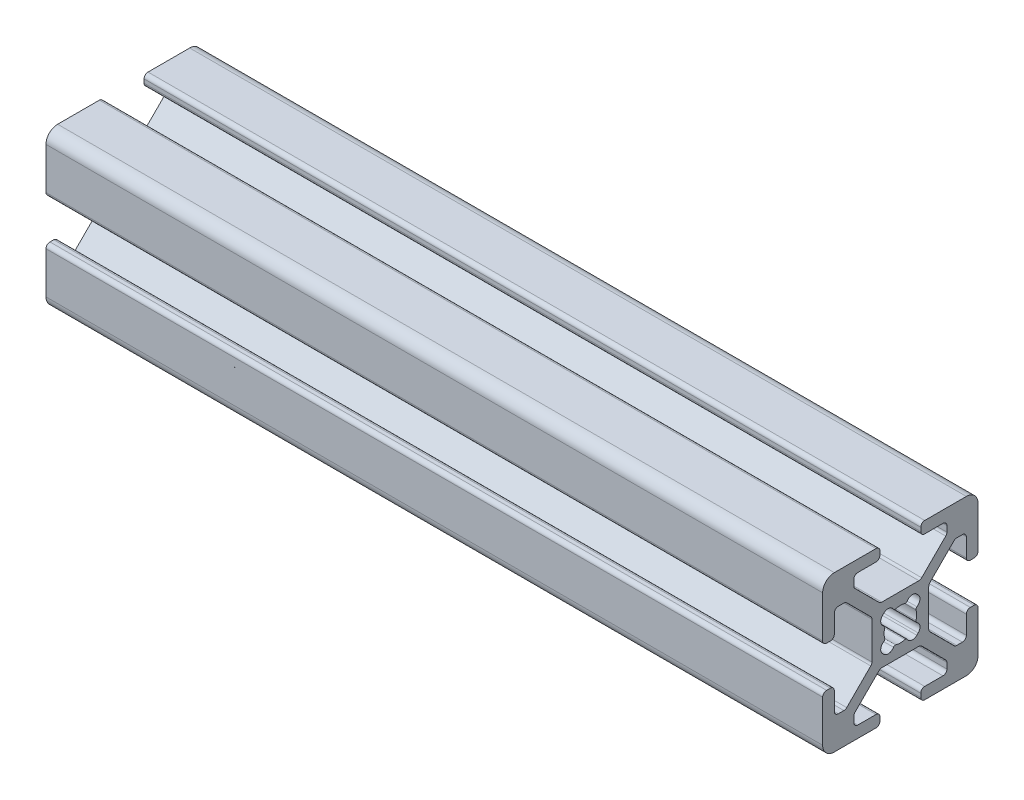
from build123d import *

# Parameters (mm, degrees)
F_20_SERIES_20_2020_1_DEPTH = 100


with BuildPart() as part:
    # Sketch11 → 20_series 20-2020(1) (new body)
    with BuildSketch(Plane.YZ):
        with BuildLine():
            Line((9.0094, 2.6289), (9.492, 2.6289))
            ThreePointArc((9.492, 2.6289), (9.851210245, 2.777689755), (10, 3.1369))
            Line((10, 3.1369), (10, 8.5014))
            ThreePointArc((10, 8.5014), (9.561070222, 9.561070222), (8.5014, 10))
            Line((8.5014, 10), (3.1369, 10))
            ThreePointArc((3.1369, 10), (2.777689755, 9.851210245), (2.6289, 9.492))
            Line((2.6289, 9.492), (2.6289, 9.0094))
            ThreePointArc((2.6289, 9.0094), (2.777689755, 8.650189755), (3.1369, 8.5014))
            Line((3.1369, 8.5014), (5.4864, 8.5014))
            ThreePointArc((5.4864, 8.5014), (5.845610245, 8.352610245), (5.9944, 7.9934))
            Line((5.9944, 7.9934), (5.9944, 7.264490712))
            ThreePointArc((5.9944, 7.264490712), (5.955730803, 7.070087528), (5.845610245, 6.905280467))
            Line((5.845610245, 6.905280467), (2.747686782, 3.807357004))
            ThreePointArc((2.747686782, 3.807357004), (2.582879721, 3.697236446), (2.388476537, 3.658567249))
            Line((2.388476537, 3.658567249), (-2.388476537, 3.658567249))
            ThreePointArc((-2.388476537, 3.658567249), (-2.582879721, 3.697236446), (-2.747686782, 3.807357004))
            Line((-2.747686782, 3.807357004), (-5.845610245, 6.905280467))
            ThreePointArc((-5.845610245, 6.905280467), (-5.955730803, 7.070087528), (-5.9944, 7.264490712))
            Line((-5.9944, 7.264490712), (-5.9944, 7.9934))
            ThreePointArc((-5.9944, 7.9934), (-5.845610245, 8.352610245), (-5.4864, 8.5014))
            Line((-5.4864, 8.5014), (-3.1369, 8.5014))
            ThreePointArc((-3.1369, 8.5014), (-2.777689755, 8.650189755), (-2.6289, 9.0094))
            Line((-2.6289, 9.0094), (-2.6289, 9.492))
            ThreePointArc((-2.6289, 9.492), (-2.777689755, 9.851210245), (-3.1369, 10))
            Line((-3.1369, 10), (-8.5014, 10))
            ThreePointArc((-8.5014, 10), (-9.561070222, 9.561070222), (-10, 8.5014))
            Line((-10, 8.5014), (-10, 3.1369))
            ThreePointArc((-10, 3.1369), (-9.851210245, 2.777689755), (-9.492, 2.6289))
            Line((-9.492, 2.6289), (-9.0094, 2.6289))
            ThreePointArc((-9.0094, 2.6289), (-8.650189755, 2.777689755), (-8.5014, 3.1369))
            Line((-8.5014, 3.1369), (-8.5014, 5.4864))
            ThreePointArc((-8.5014, 5.4864), (-8.352610245, 5.845610245), (-7.9934, 5.9944))
            Line((-7.9934, 5.9944), (-7.264490712, 5.9944))
            ThreePointArc((-7.264490712, 5.9944), (-7.070087528, 5.955730803), (-6.905280467, 5.845610245))
            Line((-6.905280467, 5.845610245), (-3.807357004, 2.747686782))
            ThreePointArc((-3.807357004, 2.747686782), (-3.697236446, 2.582879721), (-3.658567249, 2.388476537))
            Line((-3.658567249, 2.388476537), (-3.658567249, -2.388476537))
            ThreePointArc((-3.658567249, -2.388476537), (-3.697236446, -2.582879721), (-3.807357004, -2.747686782))
            Line((-3.807357004, -2.747686782), (-6.905280467, -5.845610245))
            ThreePointArc((-6.905280467, -5.845610245), (-7.070087528, -5.955730803), (-7.264490712, -5.9944))
            Line((-7.264490712, -5.9944), (-7.9934, -5.9944))
            ThreePointArc((-7.9934, -5.9944), (-8.352610245, -5.845610245), (-8.5014, -5.4864))
            Line((-8.5014, -5.4864), (-8.5014, -3.1369))
            ThreePointArc((-8.5014, -3.1369), (-8.650189755, -2.777689755), (-9.0094, -2.6289))
            Line((-9.0094, -2.6289), (-9.492, -2.6289))
            ThreePointArc((-9.492, -2.6289), (-9.851210245, -2.777689755), (-10, -3.1369))
            Line((-10, -3.1369), (-10, -8.5014))
            ThreePointArc((-10, -8.5014), (-9.561070222, -9.561070222), (-8.5014, -10))
            Line((-8.5014, -10), (-3.1369, -10))
            ThreePointArc((-3.1369, -10), (-2.777689755, -9.851210245), (-2.6289, -9.492))
            Line((-2.6289, -9.492), (-2.6289, -9.0094))
            ThreePointArc((-2.6289, -9.0094), (-2.777689755, -8.650189755), (-3.1369, -8.5014))
            Line((-3.1369, -8.5014), (-5.4864, -8.5014))
            ThreePointArc((-5.4864, -8.5014), (-5.845610245, -8.352610245), (-5.9944, -7.9934))
            Line((-5.9944, -7.9934), (-5.9944, -7.264490712))
            ThreePointArc((-5.9944, -7.264490712), (-5.955730803, -7.070087528), (-5.845610245, -6.905280467))
            Line((-5.845610245, -6.905280467), (-2.747686782, -3.807357004))
            ThreePointArc((-2.747686782, -3.807357004), (-2.582879721, -3.697236446), (-2.388476537, -3.658567249))
            Line((-2.388476537, -3.658567249), (2.388476537, -3.658567249))
            ThreePointArc((2.388476537, -3.658567249), (2.582879721, -3.697236446), (2.747686782, -3.807357004))
            Line((2.747686782, -3.807357004), (5.845610245, -6.905280467))
            ThreePointArc((5.845610245, -6.905280467), (5.955730803, -7.070087528), (5.9944, -7.264490712))
            Line((5.9944, -7.264490712), (5.9944, -7.9934))
            ThreePointArc((5.9944, -7.9934), (5.845610245, -8.352610245), (5.4864, -8.5014))
            Line((5.4864, -8.5014), (3.1369, -8.5014))
            ThreePointArc((3.1369, -8.5014), (2.777689755, -8.650189755), (2.6289, -9.0094))
            Line((2.6289, -9.0094), (2.6289, -9.492))
            ThreePointArc((2.6289, -9.492), (2.777689755, -9.851210245), (3.1369, -10))
            Line((3.1369, -10), (8.5014, -10))
            ThreePointArc((8.5014, -10), (9.561070222, -9.561070222), (10, -8.5014))
            Line((10, -8.5014), (10, -3.1369))
            ThreePointArc((10, -3.1369), (9.851210245, -2.777689755), (9.492, -2.6289))
            Line((9.492, -2.6289), (9.0094, -2.6289))
            ThreePointArc((9.0094, -2.6289), (8.650189755, -2.777689755), (8.5014, -3.1369))
            Line((8.5014, -3.1369), (8.5014, -5.4864))
            ThreePointArc((8.5014, -5.4864), (8.352610245, -5.845610245), (7.9934, -5.9944))
            Line((7.9934, -5.9944), (7.264490712, -5.9944))
            ThreePointArc((7.264490712, -5.9944), (7.070087528, -5.955730803), (6.905280467, -5.845610245))
            Line((6.905280467, -5.845610245), (3.807357004, -2.747686782))
            ThreePointArc((3.807357004, -2.747686782), (3.697236446, -2.582879721), (3.658567249, -2.388476537))
            Line((3.658567249, -2.388476537), (3.658567249, 2.388476537))
            ThreePointArc((3.658567249, 2.388476537), (3.697236446, 2.582879721), (3.807357004, 2.747686782))
            Line((3.807357004, 2.747686782), (6.905280467, 5.845610245))
            ThreePointArc((6.905280467, 5.845610245), (7.070087528, 5.955730803), (7.264490712, 5.9944))
            Line((7.264490712, 5.9944), (7.9934, 5.9944))
            ThreePointArc((7.9934, 5.9944), (8.352610245, 5.845610245), (8.5014, 5.4864))
            Line((8.5014, 5.4864), (8.5014, 3.1369))
            ThreePointArc((8.5014, 3.1369), (8.650189755, 2.777689755), (9.0094, 2.6289))
        make_face()
        with BuildLine():
            Line((-2.296558466, 2.121727546), (-2.121727546, 2.296558466))
            ThreePointArc((-2.121727546, 2.296558466), (-1.459775814, 2.520126613), (-0.880635441, 2.129282347))
            ThreePointArc((-0.880635441, 2.129282347), (-0.755121693, 2.019456424), (-0.588548999, 2.011151493))
            ThreePointArc((-0.588548999, 2.011151493), (0, 2.0955), (0.588548999, 2.011151493))
            ThreePointArc((0.588548999, 2.011151493), (0.755121693, 2.019456424), (0.880635441, 2.129282347))
            ThreePointArc((0.880635441, 2.129282347), (1.459775814, 2.520126613), (2.121727546, 2.296558466))
            Line((2.121727546, 2.296558466), (2.296558466, 2.121727546))
            ThreePointArc((2.296558466, 2.121727546), (2.520126613, 1.459775814), (2.129282347, 0.880635441))
            ThreePointArc((2.129282347, 0.880635441), (2.019456424, 0.755121693), (2.011151493, 0.588548999))
            ThreePointArc((2.011151493, 0.588548999), (2.0955, 0), (2.011151493, -0.588548999))
            ThreePointArc((2.011151493, -0.588548999), (2.019456424, -0.755121693), (2.129282347, -0.880635441))
            ThreePointArc((2.129282347, -0.880635441), (2.520126613, -1.459775814), (2.296558466, -2.121727546))
            Line((2.296558466, -2.121727546), (2.121727546, -2.296558466))
            ThreePointArc((2.121727546, -2.296558466), (1.459775814, -2.520126613), (0.880635441, -2.129282347))
            ThreePointArc((0.880635441, -2.129282347), (0.755121693, -2.019456424), (0.588548999, -2.011151493))
            ThreePointArc((0.588548999, -2.011151493), (0, -2.0955), (-0.588548999, -2.011151493))
            ThreePointArc((-0.588548999, -2.011151493), (-0.755121693, -2.019456424), (-0.880635441, -2.129282347))
            ThreePointArc((-0.880635441, -2.129282347), (-1.459775814, -2.520126613), (-2.121727546, -2.296558466))
            Line((-2.121727546, -2.296558466), (-2.296558466, -2.121727546))
            ThreePointArc((-2.296558466, -2.121727546), (-2.520126613, -1.459775814), (-2.129282347, -0.880635441))
            ThreePointArc((-2.129282347, -0.880635441), (-2.019456424, -0.755121693), (-2.011151493, -0.588548999))
            ThreePointArc((-2.011151493, -0.588548999), (-2.0955, 0), (-2.011151493, 0.588548999))
            ThreePointArc((-2.011151493, 0.588548999), (-2.019456424, 0.755121693), (-2.129282347, 0.880635441))
            ThreePointArc((-2.129282347, 0.880635441), (-2.520126613, 1.459775814), (-2.296558466, 2.121727546))
        make_face(mode=Mode.SUBTRACT)
    extrude(amount=F_20_SERIES_20_2020_1_DEPTH)


solid = part.part
